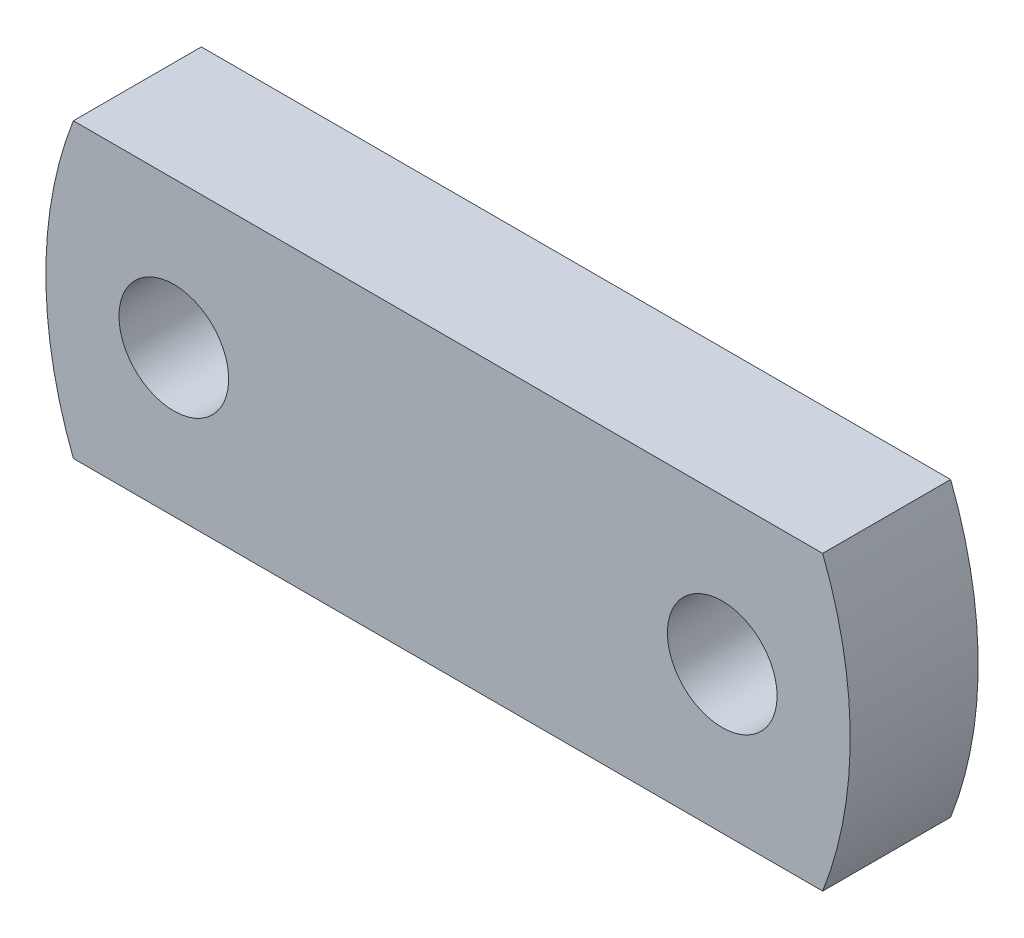
from build123d import *

# Parameters (mm, degrees)
SKETCH1_R           = 15
BOSS_EXTRUDE1_DEPTH = 35


with BuildPart() as part:
    # Sketch1 → Boss-Extrude1 (new body)
    with BuildSketch(Plane.XY):
        with BuildLine():
            Line((-102.46950766, 40), (102.46950766, 40))
            ThreePointArc((102.46950766, 40), (110, 0), (102.46950766, -40))
            Line((102.46950766, -40), (-102.46950766, -40))
            ThreePointArc((-102.46950766, -40), (-110, 0), (-102.46950766, 40))
        make_face()
        with Locations((75, 0)):
            Circle(SKETCH1_R, mode=Mode.SUBTRACT)
        with Locations((-75, 0)):
            Circle(SKETCH1_R, mode=Mode.SUBTRACT)
    extrude(amount=BOSS_EXTRUDE1_DEPTH)


solid = part.part
